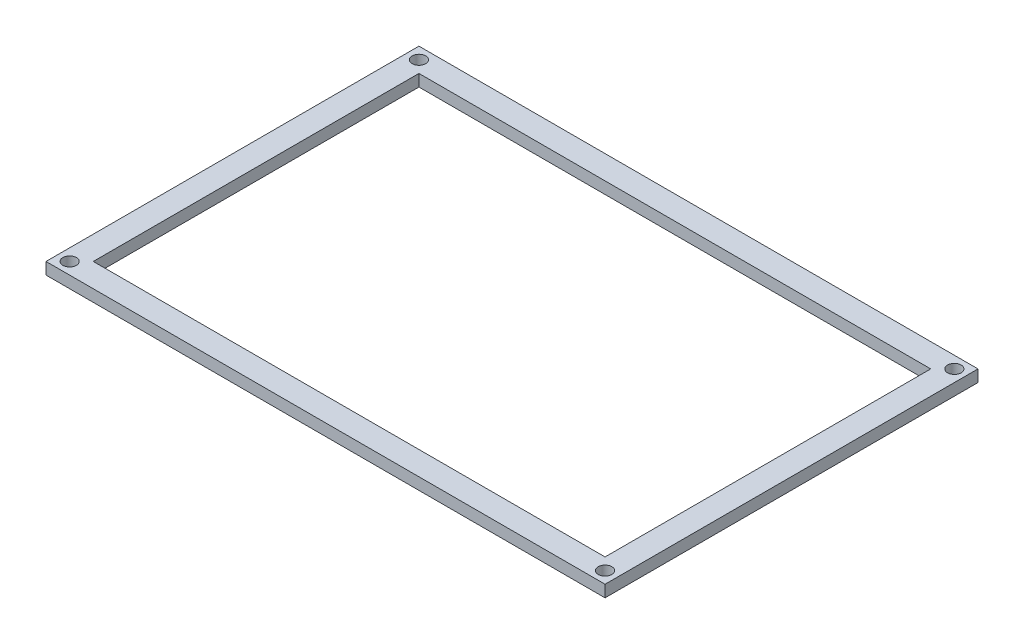
from build123d import *

# Parameters (mm, degrees)
SKETCH1_W                           = 120.160034
SKETCH1_H                           = 80.160114
SKETCH1_W_2                         = 110.000034
SKETCH1_H_2                         = 70.000114
BOSS_EXTRUDE1_DEPTH                 = 2.54
SKETCH2_R                           = 1.4605
MOUNTING_HOLES_4_40_CLEARANCE_DEPTH = 2.54


with BuildPart() as part:
    # Sketch1 → Boss-Extrude1 (new body)
    with BuildSketch(Plane(origin=(0, 0, 0), x_dir=(1, 0, 0), z_dir=(0, 1, 0))):
        Rectangle(SKETCH1_W, SKETCH1_H)
        Rectangle(SKETCH1_W_2, SKETCH1_H_2, mode=Mode.SUBTRACT)
    extrude(amount=BOSS_EXTRUDE1_DEPTH)

    # Sketch2 → Mounting Holes (4-40 Clearance) (cut)
    with BuildSketch(Plane(origin=(0, 2.54, 0), x_dir=(1, 0, 0), z_dir=(0, 1, 0))):
        with Locations((57.540017, -37.540057)):
            Circle(SKETCH2_R)
        with Locations((57.540017, 37.540057)):
            Circle(SKETCH2_R)
        with Locations((-57.540017, 37.540057)):
            Circle(SKETCH2_R)
        with Locations((-57.540017, -37.540057)):
            Circle(SKETCH2_R)
    extrude(amount=-MOUNTING_HOLES_4_40_CLEARANCE_DEPTH, mode=Mode.SUBTRACT)


solid = part.part
